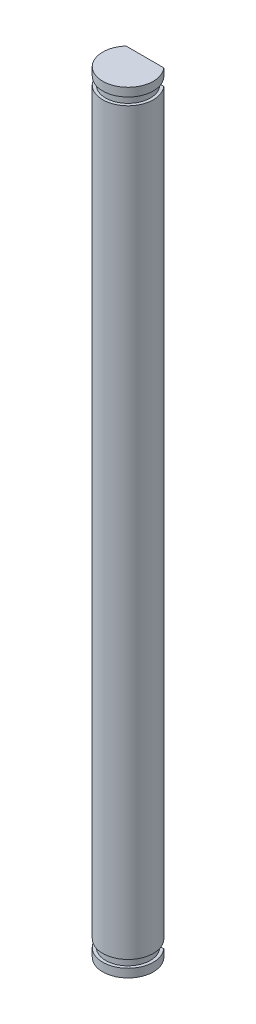
from build123d import *

# Parameters (mm, degrees)
BOSS_EXTRUDE1_DEPTH = 45.72
SKETCH2_W           = 0.35
SKETCH2_H           = 0.9


with BuildPart() as part:
    # Sketch1 → Boss-Extrude1 (new body, symmetric)
    with BuildSketch(Plane(origin=(0, 0, 0), x_dir=(1, 0, 0), z_dir=(0, 1, 0))):
        with BuildLine():
            Line((-2.236067977, 2), (2.236067977, 2))
            ThreePointArc((2.236067977, 2), (0, -3), (-2.236067977, 2))
        make_face()
    extrude(amount=BOSS_EXTRUDE1_DEPTH, both=True)

    # Sketch2 → Cut-Revolve1 (revolve, cut)
    with BuildSketch(Plane.XY):
        with Locations((2.825, 44.27)):
            Rectangle(SKETCH2_W, SKETCH2_H)
        with Locations((2.825, -44.27)):
            Rectangle(SKETCH2_W, SKETCH2_H)
    revolve(axis=Axis((0, 48.05613995, 0), (0, -1, 0)), mode=Mode.SUBTRACT)


solid = part.part
